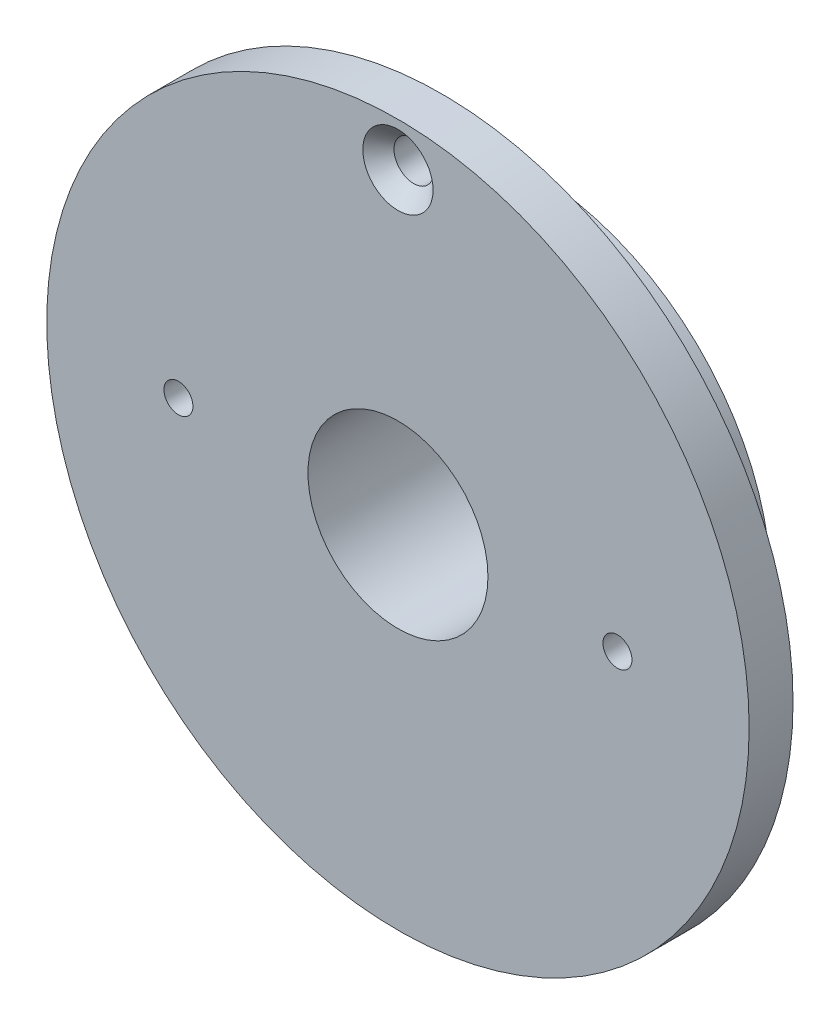
from build123d import *

# Parameters (mm, degrees)
CROQUIS1_R              = 40
SALIENTE_EXTRUIR1_DEPTH = 5
CROQUIS3_R              = 27.5
SALIENTE_EXTRUIR2_DEPTH = 10
TALADRO_ROSCADO_M41_D   = 3.3
CROQUIS6_R              = 10.25
CORTAR_EXTRUIR1_DEPTH   = 34.8


with BuildPart() as part:
    # Croquis1 → Saliente-Extruir1 (new body)
    with BuildSketch(Plane.XY):
        Circle(CROQUIS1_R)
    extrude(amount=SALIENTE_EXTRUIR1_DEPTH)

    # Croquis2 → Cortar-Revolución1 (revolve, cut)
    with BuildSketch(Plane(origin=(0, 0, 0), x_dir=(0, 0, -1), z_dir=(1, 0, 0))):
        Polygon((-5, 35), (-5, 39), (-3.2, 37.25), (0, 37.25), (0, 35), align=None)
    revolve(axis=Axis((0, 35, 20.622839442), (0, 0, -1)), mode=Mode.SUBTRACT)

    # Croquis3 → Saliente-Extruir2 (add)
    with BuildSketch(Plane(origin=(0, 0, 0), x_dir=(-1, 0, 0), z_dir=(0, 0, -1))):
        Circle(CROQUIS3_R)
    extrude(amount=SALIENTE_EXTRUIR2_DEPTH)

    # Taladro roscado M41 (through all)
    with Locations(Plane.XY.offset(5)):
        with Locations((-25, 0), (25, 0)):
            Hole(TALADRO_ROSCADO_M41_D / 2)

    # Croquis6 → Cortar-Extruir1 (cut)
    with BuildSketch(Plane.XY.offset(5)):
        Circle(CROQUIS6_R)
    extrude(amount=-CORTAR_EXTRUIR1_DEPTH, mode=Mode.SUBTRACT)


solid = part.part
